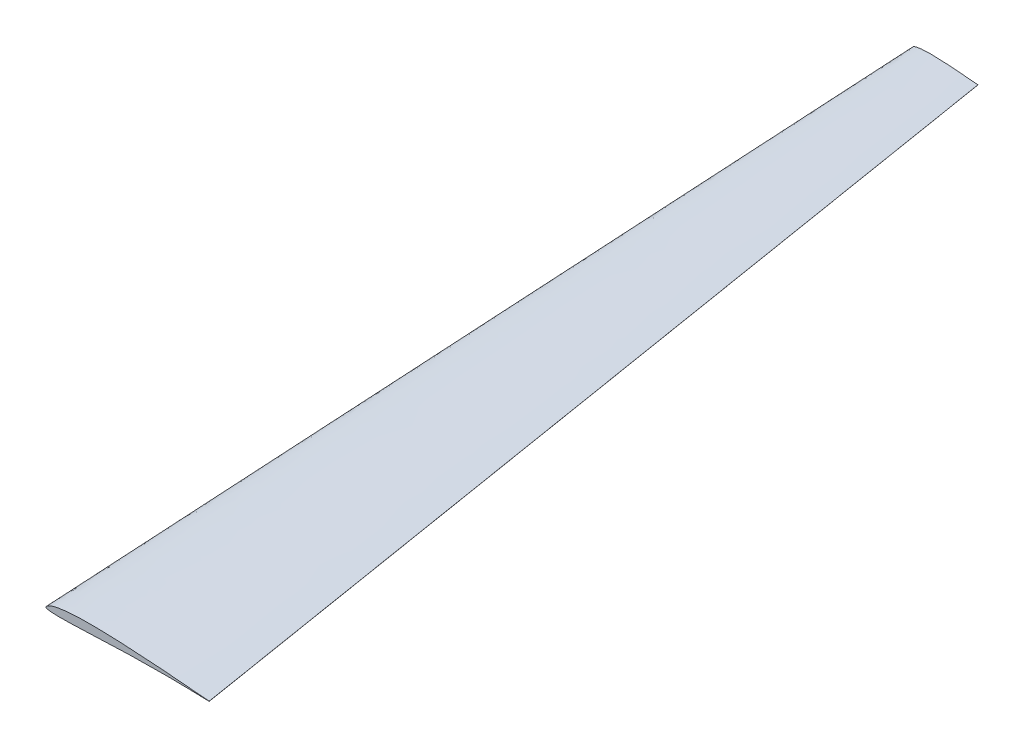
from build123d import *


with BuildPart() as part:
    # Skizze Wurzelrippe → Ausformung16 section 0
    with BuildSketch(Plane.XY):
        with BuildLine():
            Line((100, 0.048), (100, -0.048))
            add(Edge.make_bspline(
                [(100, 0.048), (95.76780906, 0.466238224), (86.962986678, 1.281660456), (73.575578397, 2.33883276), (60.766992854, 3.254117807), (49.789281318, 3.896518455), (41.105766024, 4.291136933), (33.806664906, 4.514826506), (27.437349199, 4.592654373), (21.998770096, 4.528934094), (17.497689787, 4.356644902), (13.928086723, 4.113102174), (10.845094745, 3.794315736), (8.259736488, 3.431683712), (5.771657131, 2.955533633), (3.811170609, 2.429571898), (2.4115434, 1.909402968), (1.573676426, 1.513966323), (0.858740558, 1.082335018), (0.383566208, 0.696150878), (0.095847034, 0.317390082), (-0.055093233, 0.019059873), (0.136376618, -0.363613561), (0.747212217, -0.607184857), (1.932498743, -0.906672696), (3.866879599, -1.092357286), (7.223042712, -1.236828215), (19.970315183, -1.108898541), (35.941041208, -0.168776381), (54.265204708, 0.35131035), (66.631661343, 0.514205727), (81.879716403, 0.491571988), (93.000298576, 0.162951508), (100, -0.048)],
                knots=[0, 0, 0, 0, 0.063309708, 0.131633987, 0.19990861, 0.254470332, 0.295330225, 0.329306898, 0.363176583, 0.390149151, 0.410267166, 0.430225594, 0.443403079, 0.456401114, 0.469079226, 0.48110055, 0.486575008, 0.491291364, 0.494859816, 0.499017562, 0.500262084, 0.502010583, 0.50362668, 0.506125425, 0.511427032, 0.522038169, 0.534830952, 0.561519444, 0.711640928, 0.773024385, 0.834387924, 0.895751229, 1, 1, 1, 1], degree=3))
        make_face()
    # Skizze Endrippe → Ausformung16 section 1
    with BuildSketch(Plane.XY.offset(-471.181048055)):
        with BuildLine():
            Line((100, 91.607117781), (100, 91.569517781))
            add(Edge.make_bspline(
                [(100, 91.607117781), (96.813084542, 91.915916126), (90.851601777, 92.423967443), (83.042555071, 93.020560863), (76.766219194, 93.372671012), (71.985752743, 93.511372801), (68.15118546, 93.463295528), (65.448973202, 93.282405483), (63.522885619, 93.035998392), (62.066022983, 92.741210279), (60.978168166, 92.397231129), (60.327242931, 92.020237831), (60.070984152, 91.793209931), (59.967760624, 91.558297938), (60.25906926, 91.256332084), (61.063803834, 91.128547076), (62.662524186, 90.902257484), (69.59376235, 90.844687933), (78.033126522, 91.435354055), (89.730703741, 91.748740201), (95.883656532, 91.673799724), (100, 91.569517781)],
                knots=[0, 0, 0, 0, 0.119083165, 0.222520124, 0.291273345, 0.352866804, 0.400365288, 0.433855393, 0.453552748, 0.472540107, 0.489120782, 0.495803554, 0.500290804, 0.501939697, 0.504569258, 0.514306552, 0.531773805, 0.56492964, 0.771159197, 0.846855431, 1, 1, 1, 1], degree=3))
        make_face()
    loft()


solid = part.part
